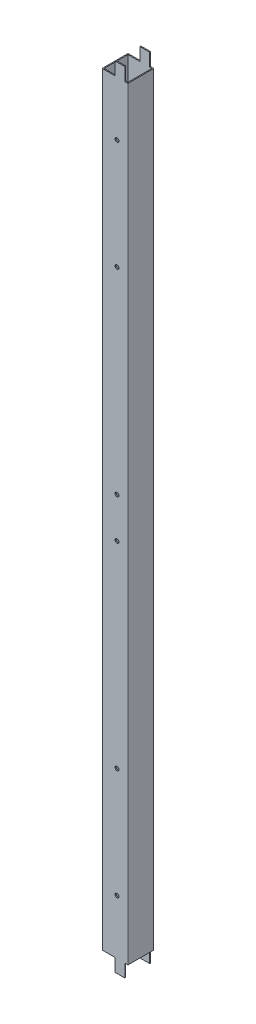
from build123d import *

# Parameters (mm, degrees)
SKETCH1_W           = 37
SKETCH1_H           = 37
BOSS_EXTRUDE1_DEPTH = 1220
SKETCH2_W           = 20
SKETCH2_H           = 20
SKETCH2_W_2         = 5
CUT_EXTRUDE1_DEPTH  = 50
CUT_EXTRUDE2_DEPTH  = 10
CUT_EXTRUDE3_DEPTH  = 10
SKETCH5_R           = 3
CUT_EXTRUDE4_DEPTH  = 1222.310771262


with BuildPart() as part:
    # Sketch1 → Boss-Extrude1 (new body)
    with BuildSketch(Plane(origin=(0, 0, 0), x_dir=(1, 0, 0), z_dir=(0, 1, 0))):
        with BuildLine():
            Line((0.5, 0), (39.5, 0))
            ThreePointArc((39.5, 0), (39.853553391, 0.146446609), (40, 0.5))
            Line((40, 0.5), (40, 39.5))
            ThreePointArc((40, 39.5), (39.853553391, 39.853553391), (39.5, 40))
            Line((39.5, 40), (0.5, 40))
            ThreePointArc((0.5, 40), (0.146446609, 39.853553391), (0, 39.5))
            Line((0, 39.5), (0, 0.5))
            ThreePointArc((0, 0.5), (0.146446609, 0.146446609), (0.5, 0))
        make_face()
        with Locations((20, 20)):
            Rectangle(SKETCH1_W, SKETCH1_H, mode=Mode.SUBTRACT)
    extrude(amount=BOSS_EXTRUDE1_DEPTH)

    # Sketch2 → Cut-Extrude1 (cut)
    with BuildSketch(Plane.XY):
        with Locations((10, 1210)):
            Rectangle(SKETCH2_W, SKETCH2_H)
        with Locations((37.5, 1210)):
            Rectangle(SKETCH2_W_2, SKETCH2_H)
        with Locations((10, 10)):
            Rectangle(SKETCH2_W, SKETCH2_H)
        with Locations((37.5, 10)):
            Rectangle(SKETCH2_W_2, SKETCH2_H)
    extrude(amount=-CUT_EXTRUDE1_DEPTH, mode=Mode.SUBTRACT)

    # Sketch3 → Cut-Extrude2 (cut)
    with BuildSketch(Plane.XY.offset(-40)):
        Polygon((30, 893.6), (20, 893.6), (20, 853.6), (30, 853.6), (30, 855.6), (22, 855.6), (22, 891.6), (30, 891.6), align=None)
        Polygon((20, 326.4), (20, 366.4), (30, 366.4), (30, 364.4), (22, 364.4), (22, 328.4), (30, 328.4), (30, 326.4), align=None)
    extrude(amount=CUT_EXTRUDE2_DEPTH, mode=Mode.SUBTRACT)

    # Sketch4 → Cut-Extrude3 (cut)
    with BuildSketch(Plane(origin=(0, 0, -40), x_dir=(-1, 0, 0), z_dir=(0, 0, -1))):
        Polygon((-30, 703.06), (-20, 703.06), (-20, 663.06), (-30, 663.06), (-30, 665.06), (-22, 665.06), (-22, 701.06), (-30, 701.06), align=None)
        Polygon((-30, 518.94), (-30, 516.94), (-20, 516.94), (-20, 556.94), (-30, 556.94), (-30, 554.94), (-22, 554.94), (-22, 518.94), align=None)
    extrude(amount=-CUT_EXTRUDE3_DEPTH, mode=Mode.SUBTRACT)

    # Sketch5 → Cut-Extrude4 (cut, through all)
    with BuildSketch(Plane(origin=(0, 0, -40), x_dir=(-1, 0, 0), z_dir=(0, 0, -1))):
        with Locations((-23, 1115.75)):
            Circle(SKETCH5_R)
        with Locations((-23, 945.75)):
            Circle(SKETCH5_R)
        with Locations((-23, 641)):
            Circle(SKETCH5_R)
        with Locations((-23, 579)):
            Circle(SKETCH5_R)
        with Locations((-23, 274.25)):
            Circle(SKETCH5_R)
        with Locations((-23, 104.25)):
            Circle(SKETCH5_R)
    extrude(amount=-CUT_EXTRUDE4_DEPTH, mode=Mode.SUBTRACT)


solid = part.part
